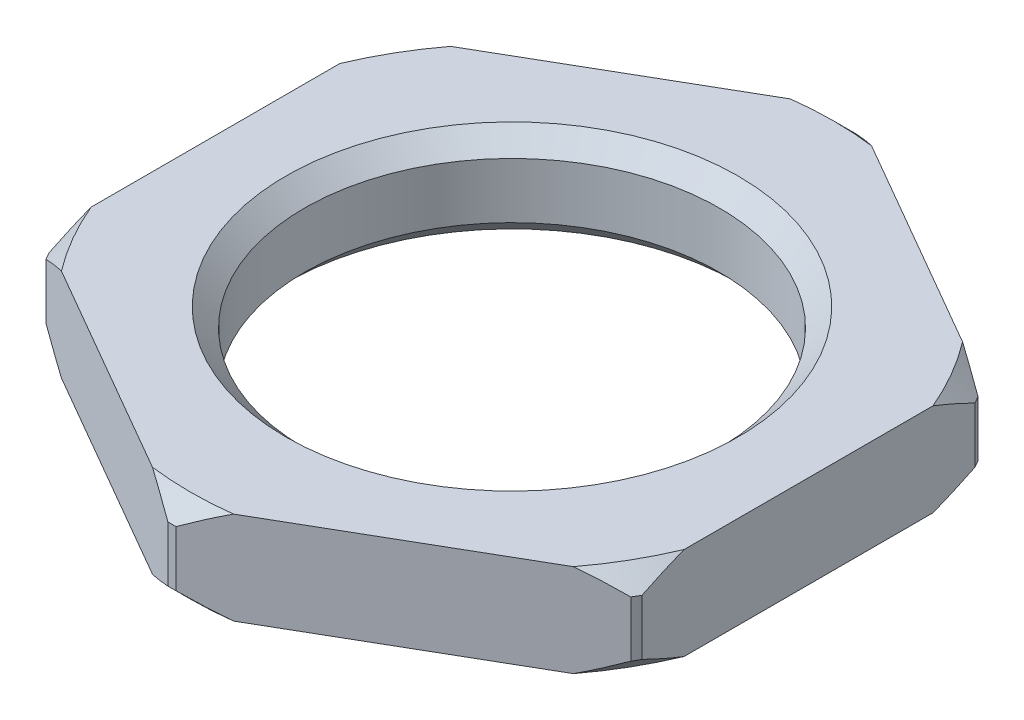
from build123d import *

# Parameters (mm, degrees)
SKETCH1_R           = 9.175
SKETCH1_R_2         = 5.6
BOSS_EXTRUDE1_DEPTH = 1.25
CHAMFER1_SIZE       = 0.5
CUT_EXTRUDE1_REACH  = 15.214
CHAMFER2_SIZE       = 0.5


with BuildPart() as part:
    # Sketch1 → Boss-Extrude1 (new, symmetric)
    with BuildSketch(Plane(origin=(0, 0, 0), x_dir=(1, 0, 0), z_dir=(0, 1, 0))):
        Circle(SKETCH1_R)
        Circle(SKETCH1_R_2, mode=Mode.SUBTRACT)
    extrude(amount=BOSS_EXTRUDE1_DEPTH, both=True)

    # Chamfer1
    chamfer1_edges = [part.edges().sort_by_distance(p)[0] for p in [
        (-9.175, -1.25, 0),
        (-9.175, 1.25, 0),
    ]]
    chamfer(chamfer1_edges, length=CHAMFER1_SIZE)

    # Sketch2 → Cut-Extrude1 (cut, up to next)
    with BuildSketch(Plane(origin=(0, 1.25, 0), x_dir=(1, 0, 0), z_dir=(0, 1, 0)), mode=Mode.PRIVATE) as cut_extrude1_sk1:
        with BuildLine():
            ThreePointArc((0.109567023, -9.174345757), (4.5875, -7.94578308), (7.890432977, -4.682060704))
            Line((7.890432977, -4.682060704), (0.109567023, -9.174345757))
        make_face()
    cut_extrude1_tool1 = extrude(cut_extrude1_sk1.sketch, amount=-CUT_EXTRUDE1_REACH, mode=Mode.PRIVATE) & part.part
    # Sketch2 → Cut-Extrude1 (cut, up to next)
    with BuildSketch(Plane(origin=(0, 1.25, 0), x_dir=(1, 0, 0), z_dir=(0, 1, 0)), mode=Mode.PRIVATE) as cut_extrude1_sk2:
        with BuildLine():
            ThreePointArc((-7.890432977, -4.682060704), (-4.5875, -7.94578308), (-0.109567023, -9.174345757))
            Line((-0.109567023, -9.174345757), (-7.890432977, -4.682060704))
        make_face()
    cut_extrude1_tool2 = extrude(cut_extrude1_sk2.sketch, amount=-CUT_EXTRUDE1_REACH, mode=Mode.PRIVATE) & part.part
    # Sketch2 → Cut-Extrude1 (cut, up to next)
    with BuildSketch(Plane(origin=(0, 1.25, 0), x_dir=(1, 0, 0), z_dir=(0, 1, 0)), mode=Mode.PRIVATE) as cut_extrude1_sk3:
        with BuildLine():
            ThreePointArc((8, -4.492285053), (9.175, 0), (8, 4.492285053))
            Line((8, 4.492285053), (8, -4.492285053))
        make_face()
    cut_extrude1_tool3 = extrude(cut_extrude1_sk3.sketch, amount=-CUT_EXTRUDE1_REACH, mode=Mode.PRIVATE) & part.part
    # Sketch2 → Cut-Extrude1 (cut, up to next)
    with BuildSketch(Plane(origin=(0, 1.25, 0), x_dir=(1, 0, 0), z_dir=(0, 1, 0)), mode=Mode.PRIVATE) as cut_extrude1_sk4:
        with BuildLine():
            ThreePointArc((-8, 4.492285053), (-9.175, 0), (-8, -4.492285053))
            Line((-8, -4.492285053), (-8, 4.492285053))
        make_face()
    cut_extrude1_tool4 = extrude(cut_extrude1_sk4.sketch, amount=-CUT_EXTRUDE1_REACH, mode=Mode.PRIVATE) & part.part
    # Sketch2 → Cut-Extrude1 (cut, up to next)
    with BuildSketch(Plane(origin=(0, 1.25, 0), x_dir=(1, 0, 0), z_dir=(0, 1, 0)), mode=Mode.PRIVATE) as cut_extrude1_sk5:
        with BuildLine():
            ThreePointArc((-0.109567023, 9.174345757), (-4.5875, 7.94578308), (-7.890432977, 4.682060704))
            Line((-7.890432977, 4.682060704), (-0.109567023, 9.174345757))
        make_face()
    cut_extrude1_tool5 = extrude(cut_extrude1_sk5.sketch, amount=-CUT_EXTRUDE1_REACH, mode=Mode.PRIVATE) & part.part
    # Sketch2 → Cut-Extrude1 (cut, up to next)
    with BuildSketch(Plane(origin=(0, 1.25, 0), x_dir=(1, 0, 0), z_dir=(0, 1, 0)), mode=Mode.PRIVATE) as cut_extrude1_sk6:
        with BuildLine():
            Line((0.109567023, 9.174345757), (7.890432977, 4.682060704))
            ThreePointArc((7.890432977, 4.682060704), (4.5875, 7.94578308), (0.109567023, 9.174345757))
        make_face()
    cut_extrude1_tool6 = extrude(cut_extrude1_sk6.sketch, amount=-CUT_EXTRUDE1_REACH, mode=Mode.PRIVATE) & part.part
    add(cut_extrude1_tool1.solids().sort_by_distance((4.23634, 1.25, 7.337555))[0], mode=Mode.SUBTRACT)
    add(cut_extrude1_tool2.solids().sort_by_distance((-4.23634, 1.25, 7.337555))[0], mode=Mode.SUBTRACT)
    add(cut_extrude1_tool3.solids().sort_by_distance((8.472679, 1.25, 0))[0], mode=Mode.SUBTRACT)
    add(cut_extrude1_tool4.solids().sort_by_distance((-8.472679, 1.25, 0))[0], mode=Mode.SUBTRACT)
    add(cut_extrude1_tool5.solids().sort_by_distance((-4.23634, 1.25, -7.337555))[0], mode=Mode.SUBTRACT)
    add(cut_extrude1_tool6.solids().sort_by_distance((4.23634, 1.25, -7.337555))[0], mode=Mode.SUBTRACT)

    # Chamfer2
    chamfer2_edges = [part.edges().sort_by_distance(p)[0] for p in [
        (-5.6, -1.25, 0),
        (-5.6, 1.25, 0),
    ]]
    chamfer(chamfer2_edges, length=CHAMFER2_SIZE)


solid = part.part
